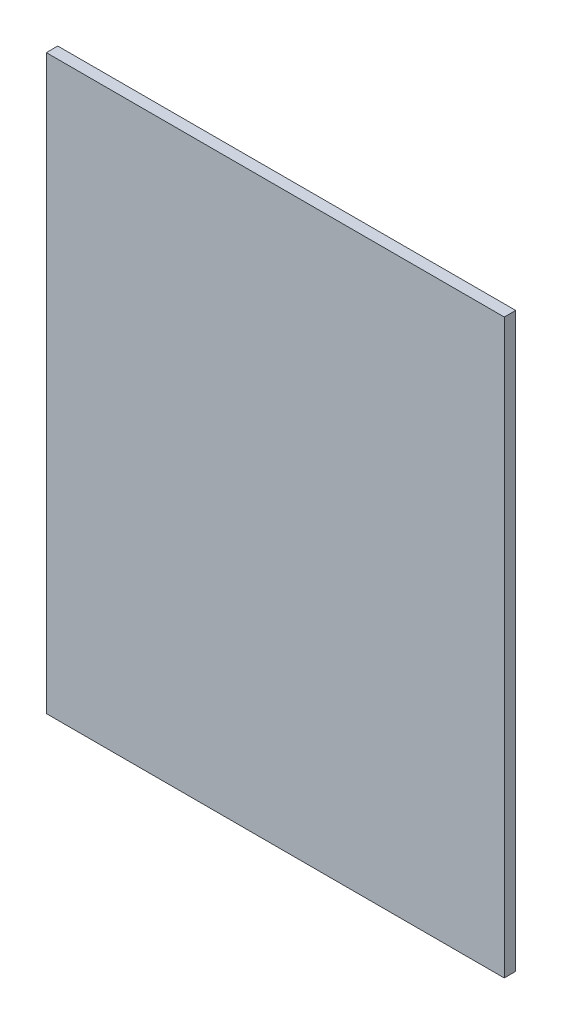
from build123d import *

# Parameters (mm, degrees)
SKETCH_1_W      = 800
SKETCH_1_H      = 1000
EXTRUDE_1_DEPTH = 20
SHELL_1_T       = -1.8


with BuildPart() as part:
    # 草图1 → 凸台-拉伸1 (new body)
    with BuildSketch(Plane.XY):
        with Locations((400, 500)):
            Rectangle(SKETCH_1_W, SKETCH_1_H)
    extrude(amount=EXTRUDE_1_DEPTH)

    # 抽壳1
    shell_1_openings = [part.faces().sort_by_distance(p)[0] for p in [
        (400, 500, 0),
    ]]
    offset(amount=SHELL_1_T, openings=shell_1_openings, kind=Kind.INTERSECTION)


solid = part.part
